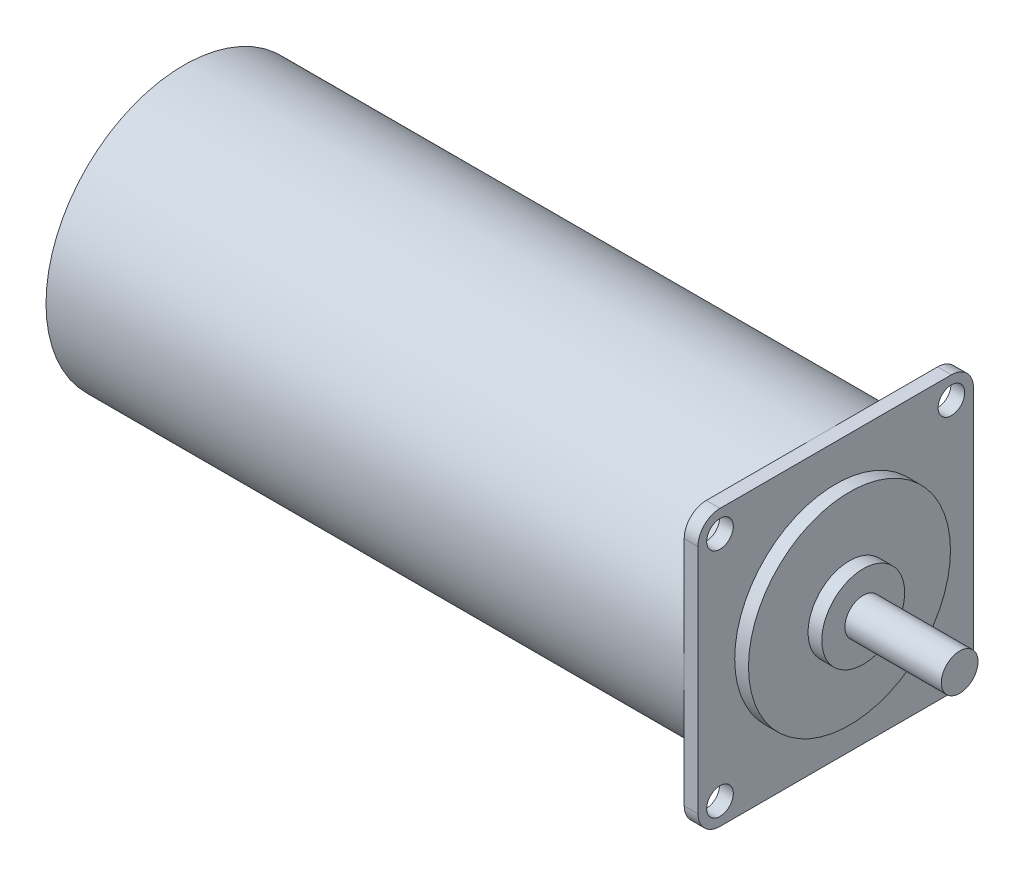
from build123d import *

# Parameters (mm, degrees)
SKETCH_2_W      = 30
SKETCH_2_H      = 30
SKETCH_2_R      = 1.45
EXTRUDE_1_DEPTH = 1.5
FILLET_1_R      = 2.4


with BuildPart() as part:
    # Эскиз1 → Повернуть1 (revolve)
    with BuildSketch(Plane.XY):
        Polygon((0, 0), (0, 15), (71, 15), (71, 11), (72.5, 11), (72.5, 4.511822107), (74, 4.511822107), (74, 2), (80, 2), (84.5, 2), (84.5, 0), align=None)
    revolve(axis=Axis((0, 0, 0), (1, 0, 0)))

    # Эскиз2 → Бобышка-Вытянуть1 (add)
    with BuildSketch(Plane(origin=(71, 0, 0), x_dir=(0, 0, -1), z_dir=(1, 0, 0))):
        Rectangle(SKETCH_2_W, SKETCH_2_H)
        with Locations((-12.6, 12.6)):
            Circle(SKETCH_2_R, mode=Mode.SUBTRACT)
        with Locations((12.6, 12.6)):
            Circle(SKETCH_2_R, mode=Mode.SUBTRACT)
        with Locations((12.6, -12.6)):
            Circle(SKETCH_2_R, mode=Mode.SUBTRACT)
        with Locations((-12.6, -12.6)):
            Circle(SKETCH_2_R, mode=Mode.SUBTRACT)
    extrude(amount=-EXTRUDE_1_DEPTH)

    # Скругление1
    fillet_1_edges = [part.edges().sort_by_distance(p)[0] for p in [
        (70.25, -15, -15),
        (70.25, -15, 15),
        (70.25, 15, 15),
        (70.25, 15, -15),
    ]]
    fillet(fillet_1_edges, radius=FILLET_1_R)


solid = part.part
